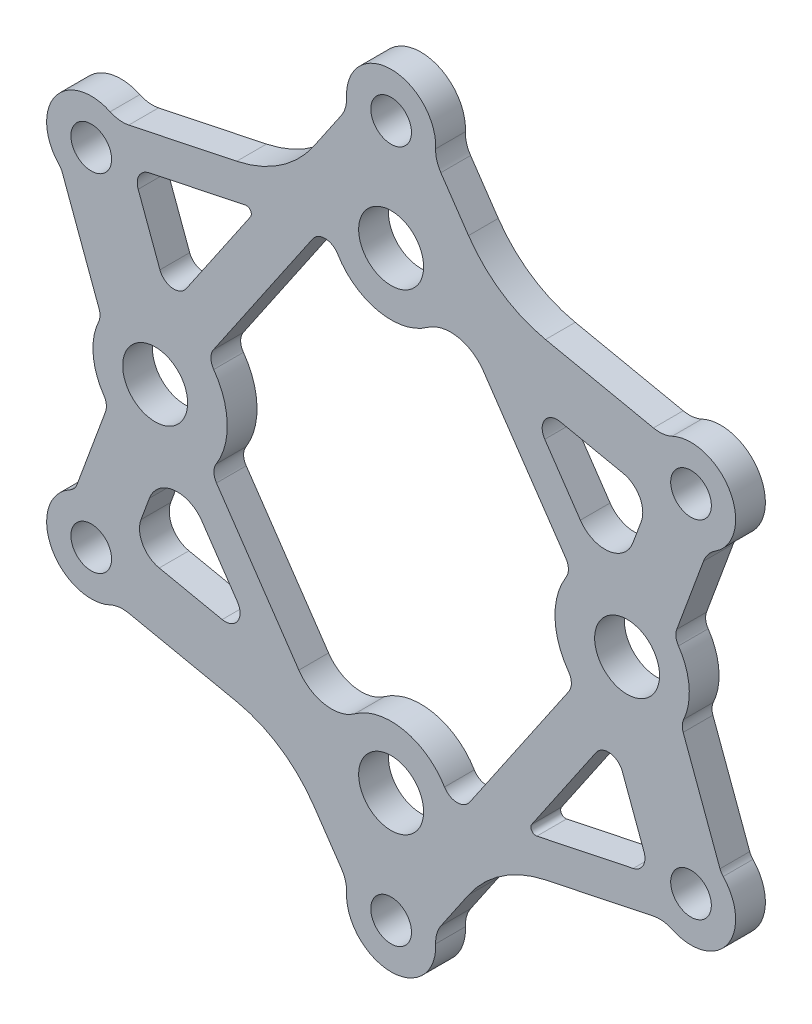
from build123d import *

# Parameters (mm, degrees)
CHAMFER1_SIZE                  = 2
SKETCH3_R                      = 4.1021
CUT_EXTRUDE2_DEPTH             = 112.883868364
SKETCH5_R                      = 6.54812
CUT_EXTRUDE3_DEPTH             = 112.883868364
SKETCH10_OUTSIDE_W             = 204.706
SKETCH10_OUTSIDE_H             = 204.706
CUT_EXTRUDELIGHTENSPIDER_DEPTH = 112.883868364


with BuildPart() as part:
    # Sketch1 → Revolve1 (revolve)
    with BuildSketch(Plane(origin=(0, 0, 0), x_dir=(0, 0, -1), z_dir=(1, 0, 0))):
        Polygon((2, 79), (6, 79), (6, 58.75), (6, 30.4), (0, 30.4), (0, 60.4), (0, 79), align=None)
    revolve(axis=Axis((0, 0, 42.402729345), (0, 0, -1)))

    # Chamfer1
    chamfer1_edges = [part.edges().sort_by_distance(p)[0] for p in [
        (0, -30.4, 0),
    ]]
    chamfer(chamfer1_edges, length=CHAMFER1_SIZE)

    # Sketch3 → Cut-Extrude2 (cut, through all)
    with BuildSketch(Plane.XY):
        with Locations((0, 69.85)):
            Circle(SKETCH3_R)
        with Locations((60.491874454, 34.925)):
            Circle(SKETCH3_R)
        with Locations((60.491874454, -34.925)):
            Circle(SKETCH3_R)
        with Locations((0, -69.85)):
            Circle(SKETCH3_R)
        with Locations((-60.491874454, -34.925)):
            Circle(SKETCH3_R)
        with Locations((-60.491874454, 34.925)):
            Circle(SKETCH3_R)
    extrude(amount=-CUT_EXTRUDE2_DEPTH, mode=Mode.SUBTRACT)

    # Sketch5 → Cut-Extrude3 (cut, through all)
    with BuildSketch(Plane.XY):
        with Locations((0, 47.6)):
            Circle(SKETCH5_R)
        with Locations((47.6, 0)):
            Circle(SKETCH5_R)
        with Locations((0, -47.6)):
            Circle(SKETCH5_R)
        with Locations((-47.6, 0)):
            Circle(SKETCH5_R)
    extrude(amount=-CUT_EXTRUDE3_DEPTH, mode=Mode.SUBTRACT)

    # Sketch10 outside → Cut-ExtrudeLightenSpider (cut, through all)
    # profile 1 of 6: a face of its own
    with BuildSketch(Plane.XY):
        Rectangle(SKETCH10_OUTSIDE_W, SKETCH10_OUTSIDE_H)
        with BuildLine():
            Line((-10.026404015, 65.791524605), (-15.612126757, 57.594828522))
            ThreePointArc((-15.612126757, 57.594828522), (-22.370889622, 50.893885768), (-31.144282145, 47.204564302))
            Line((-31.144282145, 47.204564302), (-52.913637786, 42.643181716))
            ThreePointArc((-52.913637786, 42.643181716), (-54.833820547, 42.555428057), (-56.683216005, 43.079392731))
            ThreePointArc((-56.683216005, 43.079392731), (-67.808926528, 40.165300464), (-66.985857737, 28.693773706))
            ThreePointArc((-66.985857737, 28.693773706), (-66.607453407, 28.208181309), (-66.336137509, 27.655571594))
            Line((-66.336137509, 27.655571594), (-58.910187887, 7.538148679))
            ThreePointArc((-58.910187887, 7.538148679), (-58.726829376, 6.382845568), (-58.999242441, 5.245244256))
            ThreePointArc((-58.999242441, 5.245244256), (-60.103553413, -1.056630301), (-57.957357907, -7.083816253))
            ThreePointArc((-57.957357907, -7.083816253), (-57.456302519, -8.408967742), (-57.619209975, -9.816285805))
            Line((-57.619209975, -9.816285805), (-63.372036652, -25.401100289))
            ThreePointArc((-63.372036652, -25.401100289), (-63.921102493, -26.329038035), (-64.762782095, -27.002920227))
            ThreePointArc((-64.762782095, -27.002920227), (-68.5334328, -38.966452632), (-56.683216005, -43.079392731))
            ThreePointArc((-56.683216005, -43.079392731), (-54.833820547, -42.555428057), (-52.913637786, -42.643181716))
            Line((-52.913637786, -42.643181716), (-31.144282145, -47.204564302))
            ThreePointArc((-31.144282145, -47.204564302), (-22.370889622, -50.893885768), (-15.612126757, -57.594828522))
            Line((-15.612126757, -57.594828522), (-10.026404015, -65.791524605))
            ThreePointArc((-10.026404015, -65.791524605), (-9.212368611, -67.53283127), (-8.990756336, -69.442200417))
            ThreePointArc((-8.990756336, -69.442200417), (0, -78.85), (8.990756336, -69.442200417))
            ThreePointArc((8.990756336, -69.442200417), (9.212368611, -67.53283127), (10.026404015, -65.791524605))
            Line((10.026404015, -65.791524605), (15.612126757, -57.594828522))
            ThreePointArc((15.612126757, -57.594828522), (22.370889622, -50.893885768), (31.144282145, -47.204564302))
            Line((31.144282145, -47.204564302), (52.913637786, -42.643181716))
            ThreePointArc((52.913637786, -42.643181716), (54.833820547, -42.555428057), (56.683216005, -43.079392731))
            ThreePointArc((56.683216005, -43.079392731), (67.808926528, -40.165300464), (66.985857737, -28.693773706))
            ThreePointArc((66.985857737, -28.693773706), (66.607453407, -28.208181309), (66.336137509, -27.655571594))
            Line((66.336137509, -27.655571594), (58.910187887, -7.538148679))
            ThreePointArc((58.910187887, -7.538148679), (58.726829376, -6.382845568), (58.999242441, -5.245244256))
            ThreePointArc((58.999242441, -5.245244256), (60.103553413, 1.056630301), (57.957357907, 7.083816253))
            ThreePointArc((57.957357907, 7.083816253), (57.456302519, 8.408967742), (57.619209975, 9.816285805))
            Line((57.619209975, 9.816285805), (63.004017141, 24.404109395))
            ThreePointArc((63.004017141, 24.404109395), (63.949907854, 26.077457327), (65.376417653, 27.365817654))
            ThreePointArc((65.376417653, 27.365817654), (68.367056511, 39.2817772), (56.683216005, 43.079392731))
            ThreePointArc((56.683216005, 43.079392731), (54.833820547, 42.555428057), (52.913637786, 42.643181716))
            Line((52.913637786, 42.643181716), (31.144282145, 47.204564302))
            ThreePointArc((31.144282145, 47.204564302), (22.370889622, 50.893885768), (15.612126757, 57.594828522))
            Line((15.612126757, 57.594828522), (10.026404015, 65.791524605))
            ThreePointArc((10.026404015, 65.791524605), (9.212368611, 67.53283127), (8.990756336, 69.442200417))
            ThreePointArc((8.990756336, 69.442200417), (0, 78.85), (-8.990756336, 69.442200417))
            ThreePointArc((-8.990756336, 69.442200417), (-9.212368611, 67.53283127), (-10.026404015, 65.791524605))
        make_face(mode=Mode.SUBTRACT)
    # profile 2 of 6: a face of its own
    with BuildSketch(Plane.XY):
        with BuildLine():
            Line((-38.171337153, -19.163288775), (-30.989327096, -29.702435886))
            ThreePointArc((-30.989327096, -29.702435886), (-30.974904193, -33.059883994), (-34.083658328, -34.328077016))
            Line((-34.083658328, -34.328077016), (-46.782801613, -31.667196649))
            ThreePointArc((-46.782801613, -31.667196649), (-50.132508933, -29.193901063), (-50.448043328, -25.042013753))
            Line((-50.448043328, -25.042013753), (-48.758289676, -20.464351561))
            ThreePointArc((-48.758289676, -20.464351561), (-43.861379511, -16.586899466), (-38.171337153, -19.163288775))
        make_face()
    # profile 3 of 6: a face of its own
    with BuildSketch(Plane.XY):
        with BuildLine():
            Line((-48.823135839, 36.348261242), (-29.399536951, 40.418132082))
            ThreePointArc((-29.399536951, 40.418132082), (-28.363285572, 39.995401074), (-28.368093206, 38.876251705))
            Line((-28.368093206, 38.876251705), (-41.341857561, 19.838070188))
            ThreePointArc((-41.341857561, 19.838070188), (-44.186878741, 18.549875534), (-46.635333823, 20.488601581))
            Line((-46.635333823, 20.488601581), (-51.022280868, 32.373151504))
            ThreePointArc((-51.022280868, 32.373151504), (-50.832960232, 34.86428389), (-48.823135839, 36.348261242))
        make_face()
    # profile 4 of 6: a face of its own
    with BuildSketch(Plane.XY):
        with BuildLine():
            Line((46.635333823, -20.488601581), (51.022280868, -32.373151504))
            ThreePointArc((51.022280868, -32.373151504), (50.832960232, -34.86428389), (48.823135839, -36.348261242))
            Line((48.823135839, -36.348261242), (29.399536951, -40.418132082))
            ThreePointArc((29.399536951, -40.418132082), (28.363285572, -39.995401074), (28.368093206, -38.876251705))
            Line((28.368093206, -38.876251705), (41.341857561, -19.838070188))
            ThreePointArc((41.341857561, -19.838070188), (44.186878741, -18.549875534), (46.635333823, -20.488601581))
        make_face()
    # profile 5 of 6: a face of its own
    with BuildSketch(Plane.XY):
        with BuildLine():
            Line((34.083658328, 34.328077016), (46.782801613, 31.667196649))
            ThreePointArc((46.782801613, 31.667196649), (50.132508933, 29.193901063), (50.448043328, 25.042013753))
            Line((50.448043328, 25.042013753), (48.758289676, 20.464351561))
            ThreePointArc((48.758289676, 20.464351561), (43.861379511, 16.586899466), (38.171337153, 19.163288775))
            Line((38.171337153, 19.163288775), (30.989327096, 29.702435886))
            ThreePointArc((30.989327096, 29.702435886), (30.974904193, 33.059883994), (34.083658328, 34.328077016))
        make_face()
    # profile 6 of 6: a face of its own
    with BuildSketch(Plane.XY):
        with BuildLine():
            Line((-15.821171438, 41.306107758), (-35.834530202, 11.937765116))
            ThreePointArc((-35.834530202, 11.937765116), (-36.35519159, 10.21012461), (-35.790664462, 8.496316242))
            ThreePointArc((-35.790664462, 8.496316242), (-33.058727226, 0.446297704), (-35.291848474, -7.756107371))
            ThreePointArc((-35.291848474, -7.756107371), (-35.75327476, -9.409318188), (-35.232852266, -11.044916137))
            Line((-35.232852266, -11.044916137), (-18.616205445, -35.42879808))
            ThreePointArc((-18.616205445, -35.42879808), (-13.39288563, -38.802460256), (-7.331267504, -37.416295746))
            ThreePointArc((-7.331267504, -37.416295746), (2.539818576, -35.311605592), (10.767731208, -41.157075185))
            ThreePointArc((10.767731208, -41.157075185), (13.253641017, -42.61539929), (15.821171438, -41.306107758))
            Line((15.821171438, -41.306107758), (35.834530202, -11.937765117))
            ThreePointArc((35.834530202, -11.937765117), (36.35519159, -10.21012461), (35.790664462, -8.496316242))
            ThreePointArc((35.790664462, -8.496316242), (33.058727226, -0.446297704), (35.291848474, 7.756107371))
            ThreePointArc((35.291848474, 7.756107371), (35.75327476, 9.409318188), (35.232852266, 11.044916137))
            Line((35.232852266, 11.044916137), (18.616205445, 35.42879808))
            ThreePointArc((18.616205445, 35.42879808), (13.39288563, 38.802460256), (7.331267504, 37.416295746))
            ThreePointArc((7.331267504, 37.416295746), (-2.539818576, 35.311605592), (-10.767731208, 41.157075185))
            ThreePointArc((-10.767731208, 41.157075185), (-13.253641017, 42.61539929), (-15.821171438, 41.306107758))
        make_face()
    extrude(amount=-CUT_EXTRUDELIGHTENSPIDER_DEPTH, mode=Mode.SUBTRACT)


solid = part.part
